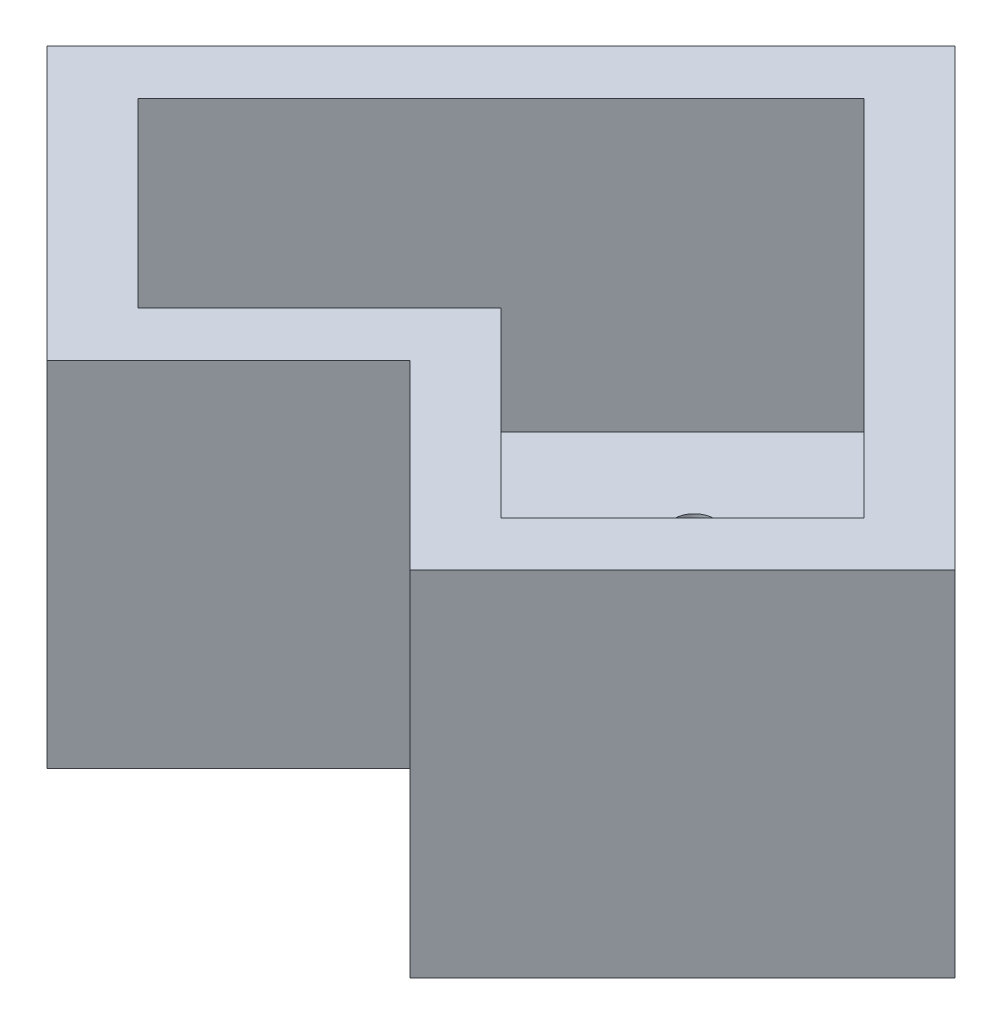
from build123d import *

# Parameters (mm, degrees)
BOSS_EXTRUDE1_DEPTH = 11
SHELL1_T            = -2
SKETCH3_R           = 0.625
CUT_EXTRUDE1_DEPTH  = 10


with BuildPart() as part:
    # Sketch1 → Boss-Extrude1 (new body)
    with BuildSketch(Plane(origin=(0, 0, 0), x_dir=(1, 0, 0), z_dir=(0, 1, 0))):
        Polygon((0, 0), (5.656854249, -5.656854249), (14.142135624, 2.828427125), (0, 16.970562748), (-14.142135624, 2.828427125), (-5.656854249, -5.656854249), align=None)
    extrude(amount=BOSS_EXTRUDE1_DEPTH)

    # Shell1
    shell1_openings = [part.faces().sort_by_distance(p)[0] for p in [
        (0, 11, -1.885618083),
    ]]
    offset(amount=SHELL1_T, openings=shell1_openings, kind=Kind.INTERSECTION)

    # Sketch3 → Cut-Extrude1 (cut)
    with BuildSketch(Plane.XZ):
        with Locations((-5.656854249, -1.558427125)):
            Circle(SKETCH3_R)
        with Locations((-5.656854249, -4.098427125)):
            Circle(SKETCH3_R)
        with Locations((0, -6.308427125)):
            Circle(SKETCH3_R)
        with Locations((0, -8.848427125)):
            Circle(SKETCH3_R)
        with Locations((5.656854249, -1.558427125)):
            Circle(SKETCH3_R)
        with Locations((5.656854249, -4.098427125)):
            Circle(SKETCH3_R)
    extrude(amount=-CUT_EXTRUDE1_DEPTH, mode=Mode.SUBTRACT)


solid = part.part
